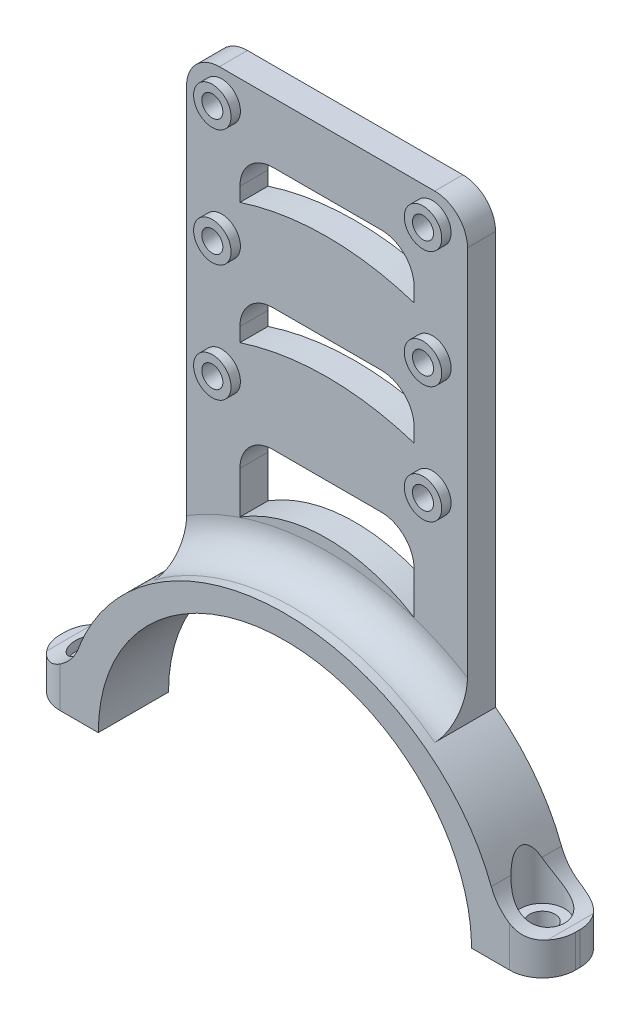
from build123d import *

# Parameters (mm, degrees)
BOSS_EXTRUDE1_DEPTH     = 15
FILLET1_R               = 10
SKETCH3_R               = 2.7
CUT_EXTRUDE1_DEPTH      = 17
CUT_EXTRUDE2_DEPTH      = 12
CUT_EXTRUDE2_DEPTH_BACK = 1
SKETCH3_4_R             = 2.7
SKETCH5_R               = 4.75
CUT_EXTRUDE3_DEPTH      = 17
SKETCH6_R               = 2.25
BOSS_EXTRUDE6_DEPTH     = 6
FILLET7_R               = 7
FILLET8_R               = 7
FILLET9_R               = 7
FILLET10_R              = 7
SKETCH8_R               = 4
SKETCH8_R_2             = 2.25
BOSS_EXTRUDE7_DEPTH     = 2


with BuildPart() as part:
    # Sketch1 → Boss-Extrude1 (new body)
    with BuildSketch(Plane.XY):
        with BuildLine():
            Line((-39.855, 0), (-55.024390244, 0))
            Line((-55.024390244, 0), (-55.024390244, 7.011281463))
            Line((-55.024390244, 7.011281463), (-45.900914662, 6.989739898))
            add(Edge.make_bspline(
                [(45.900914662, 6.989739898), (39.351881023, 42), (0, 42), (-39.351881023, 42), (-45.900914662, 6.989739898)],
                knots=[3.308792985, 3.308792985, 3.308792985, 4.71238898, 4.71238898, 6.115984976, 6.115984976, 6.115984976], degree=2, weights=[1, 0.76368265, 1, 0.76368265, 1]))
            Line((45.900914662, 6.989739898), (55.024390244, 7.011281463))
            Line((55.024390244, 7.011281463), (55.024390244, 0))
            Line((55.024390244, 0), (39.855, 0))
            add(Edge.make_bspline(
                [(39.855, 0), (39.855, 37), (0, 37), (-39.855, 37), (-39.855, 0)],
                knots=[0, 0, 0, 1.570796327, 1.570796327, 3.141592654, 3.141592654, 3.141592654], degree=2, weights=[1, 0.707106781, 1, 0.707106781, 1]))
        make_face()
    extrude(amount=BOSS_EXTRUDE1_DEPTH)

    # Fillet1
    fillet1_edges = [part.edges().sort_by_distance(p)[0] for p in [
        (45.900914662, 6.989739898, 7.5),
        (-45.900914662, 6.989739898, 7.5),
    ]]
    fillet(fillet1_edges, radius=FILLET1_R)

    # Sketch3 → Cut-Extrude1 (cut)
    with BuildSketch(Plane(origin=(0, 0, 0), x_dir=(1, 0, 0), z_dir=(0, 1, 0))):
        with Locations((-47.5, -7.5)):
            Circle(SKETCH3_R)
    extrude(amount=CUT_EXTRUDE1_DEPTH, mode=Mode.SUBTRACT)

    # Sketch3_4 → Cut-Extrude2 (cut, two sides: drawn at the far end of the back side and taken through both)
    with BuildSketch(Plane(origin=(0, 0, 0), x_dir=(1, 0, 0), z_dir=(0, 1, 0)).offset(-CUT_EXTRUDE2_DEPTH_BACK)):
        with Locations((47.5, -7.5)):
            Circle(SKETCH3_4_R)
        with Locations((-47.5, -7.5)):
            Circle(SKETCH3_4_R)
    extrude(amount=CUT_EXTRUDE2_DEPTH + CUT_EXTRUDE2_DEPTH_BACK, mode=Mode.SUBTRACT)

    # Sketch5 → Cut-Extrude3 (cut)
    with BuildSketch(Plane(origin=(0, 5, 0), x_dir=(1, 0, 0), z_dir=(0, 1, 0))):
        with Locations((-47.5, -7.5)):
            Circle(SKETCH5_R)
        with Locations((47.5, -7.5)):
            Circle(SKETCH5_R)
    extrude(amount=CUT_EXTRUDE3_DEPTH, mode=Mode.SUBTRACT)

    # Sketch6 → Boss-Extrude6 (add)
    with BuildSketch(Plane.XY):
        with BuildLine():
            Line((30, 127.114539993), (-30, 127.114539993))
            Line((-30, 127.114539993), (-30, 32.114539993))
            ThreePointArc((-30, 32.114539993), (0, 41.016817706), (30, 32.114539993))
            Line((30, 32.114539993), (30, 127.114539993))
        make_face()
        with Locations((22.5, 121.114539993)):
            Circle(SKETCH6_R, mode=Mode.SUBTRACT)
        with Locations((-22.5, 121.114539993)):
            Circle(SKETCH6_R, mode=Mode.SUBTRACT)
        with Locations((-22.5, 96.114539993)):
            Circle(SKETCH6_R, mode=Mode.SUBTRACT)
        with Locations((-22.5, 71.114539993)):
            Circle(SKETCH6_R, mode=Mode.SUBTRACT)
        with Locations((22.5, 96.114539993)):
            Circle(SKETCH6_R, mode=Mode.SUBTRACT)
        with Locations((22.5, 71.114539993)):
            Circle(SKETCH6_R, mode=Mode.SUBTRACT)
        with BuildLine():
            Line((18.600416941, 62.016817706), (18.600416941, 46.016817706))
            ThreePointArc((18.600416941, 46.016817706), (0, 51.368470541), (-18.600416941, 46.016817706))
            Line((-18.600416941, 46.016817706), (-18.600416941, 62.016817706))
            Line((-18.600416941, 62.016817706), (18.600416941, 62.016817706))
        make_face(mode=Mode.SUBTRACT)
        with BuildLine():
            Line((18.600416941, 88.26638462), (18.600416941, 78.26638462))
            ThreePointArc((18.600416941, 78.26638462), (0, 81.222327177), (-18.600416941, 78.26638462))
            Line((-18.600416941, 78.26638462), (-18.600416941, 88.26638462))
            Line((-18.600416941, 88.26638462), (18.600416941, 88.26638462))
        make_face(mode=Mode.SUBTRACT)
        with BuildLine():
            Line((-18.600416941, 114.210705635), (-18.600416941, 104.210705635))
            ThreePointArc((-18.600416941, 104.210705635), (0, 107.166648192), (18.600416941, 104.210705635))
            Line((18.600416941, 104.210705635), (18.600416941, 114.210705635))
            Line((18.600416941, 114.210705635), (-18.600416941, 114.210705635))
        make_face(mode=Mode.SUBTRACT)
    extrude(amount=BOSS_EXTRUDE6_DEPTH)

    # Fillet7
    fillet7_edges = [part.edges().sort_by_distance(p)[0] for p in [
        (-18.600416941, 62.016817706, 3),
        (18.600416941, 62.016817706, 3),
        (18.600416941, 88.26638462, 3),
        (-18.600416941, 88.26638462, 3),
        (-18.600416941, 114.210705635, 3),
        (18.600416941, 114.210705635, 3),
        (30, 127.114539993, 3),
        (-30, 127.114539993, 3),
    ]]
    fillet(fillet7_edges, radius=FILLET7_R)

    # Fillet8
    fillet8_edges = [part.edges().sort_by_distance(p)[0] for p in [
        (-55.024390244, 3.505640732, 15),
        (-55.024390244, 3.505640732, 0),
    ]]
    fillet(fillet8_edges, radius=FILLET8_R)

    # Fillet9
    fillet9_edges = [part.edges().sort_by_distance(p)[0] for p in [
        (55.024390244, 3.505640732, 15),
        (55.024390244, 3.505640732, 0),
    ]]
    fillet(fillet9_edges, radius=FILLET9_R)

    # Fillet10
    fillet10_edges = [part.edges().sort_by_distance(p)[0] for p in [
        (0, 42, 6),
    ]]
    fillet(fillet10_edges, radius=FILLET10_R)

    # Sketch8 → Boss-Extrude7 (add)
    # profile 1 of 6: a face of its own
    with BuildSketch(Plane.XY.offset(6)):
        with Locations((-22.5, 121.114539993)):
            Circle(SKETCH8_R)
        with Locations((-22.5, 121.114539993)):
            Circle(SKETCH8_R_2, mode=Mode.SUBTRACT)
    # profile 2 of 6: a face of its own
    with BuildSketch(Plane.XY.offset(6)):
        with Locations((22.5, 121.114539993)):
            Circle(SKETCH8_R)
        with Locations((22.5, 121.114539993)):
            Circle(SKETCH8_R_2, mode=Mode.SUBTRACT)
    # profile 3 of 6: a face of its own
    with BuildSketch(Plane.XY.offset(6)):
        with Locations((-22.5, 96.114539993)):
            Circle(SKETCH8_R)
        with Locations((-22.5, 96.114539993)):
            Circle(SKETCH8_R_2, mode=Mode.SUBTRACT)
    # profile 4 of 6: a face of its own
    with BuildSketch(Plane.XY.offset(6)):
        with Locations((22.5, 96.114539993)):
            Circle(SKETCH8_R)
        with Locations((22.5, 96.114539993)):
            Circle(SKETCH8_R_2, mode=Mode.SUBTRACT)
    # profile 5 of 6: a face of its own
    with BuildSketch(Plane.XY.offset(6)):
        with Locations((22.5, 71.114539993)):
            Circle(SKETCH8_R)
        with Locations((22.5, 71.114539993)):
            Circle(SKETCH8_R_2, mode=Mode.SUBTRACT)
    # profile 6 of 6: a face of its own
    with BuildSketch(Plane.XY.offset(6)):
        with Locations((-22.5, 71.114539993)):
            Circle(SKETCH8_R)
        with Locations((-22.5, 71.114539993)):
            Circle(SKETCH8_R_2, mode=Mode.SUBTRACT)
    extrude(amount=BOSS_EXTRUDE7_DEPTH)


solid = part.part
